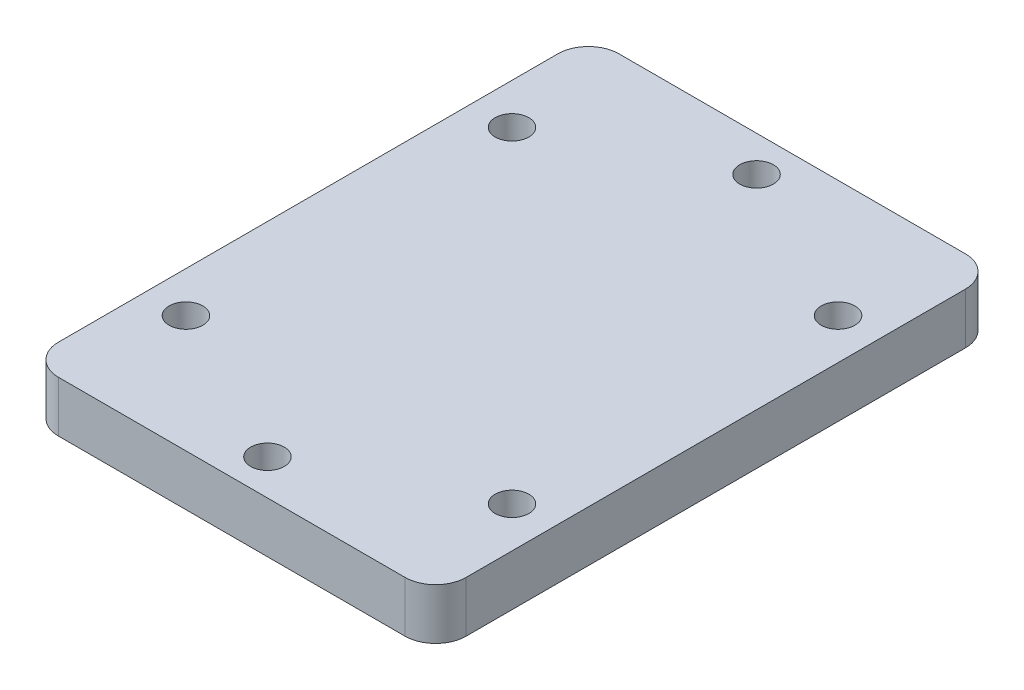
from build123d import *

# Parameters (mm, degrees)
SKETCH_1_W          = 40
SKETCH_1_H          = 55
SKETCH_1_R          = 1.65
EXTRUDE_1_DEPTH     = 5
EXTRUDE_2_DEPTH     = 3
SKETCH_3_R          = 1.65
CUT_EXTRUDE_1_DEPTH = 8.5
CUT_EXTRUDE_2_DEPTH = 2.5
FILLET_1_R          = 3


with BuildPart() as part:
    # 草图1 → 凸台-拉伸1 (new body)
    with BuildSketch(Plane(origin=(0, 0, 0), x_dir=(1, 0, 0), z_dir=(0, 1, 0))):
        Rectangle(SKETCH_1_W, SKETCH_1_H)
        with Locations((-16, 16)):
            Circle(SKETCH_1_R, mode=Mode.SUBTRACT)
        with Locations((16, 16)):
            Circle(SKETCH_1_R, mode=Mode.SUBTRACT)
        with Locations((16, -16)):
            Circle(SKETCH_1_R, mode=Mode.SUBTRACT)
        with Locations((-16, -16)):
            Circle(SKETCH_1_R, mode=Mode.SUBTRACT)
    extrude(amount=EXTRUDE_1_DEPTH)

    # 草图2 → 凸台-拉伸2 (add, symmetric)
    with BuildSketch(Plane(origin=(0, 0, 0), x_dir=(0, 0, -1), z_dir=(1, 0, 0))):
        Polygon((-18.5, 0), (-8.5, 0), (-11, -2.5), (-16, -2.5), align=None)
        Polygon((11, -2.5), (16, -2.5), (18.5, 0), (8.5, 0), align=None)
    extrude(amount=EXTRUDE_2_DEPTH, both=True)

    # 草图3 → 切除-拉伸1 (cut, through all)
    with BuildSketch(Plane(origin=(0, 5, 0), x_dir=(1, 0, 0), z_dir=(0, 1, 0))):
        with Locations((0, -24)):
            Circle(SKETCH_3_R)
        with Locations((0, 24)):
            Circle(SKETCH_3_R)
    extrude(amount=-CUT_EXTRUDE_1_DEPTH, mode=Mode.SUBTRACT)

    # 草图4 → 切除-拉伸2 (cut)
    with BuildSketch(Plane.XZ):
        Polygon((-14.383419246, 18.8), (-17.616580754, 18.8), (-19.233161507, 16), (-17.616580754, 13.2), (-14.383419246, 13.2), (-12.766838493, 16), align=None)
        Polygon((17.616580754, 18.8), (14.383419246, 18.8), (12.766838493, 16), (14.383419246, 13.2), (17.616580754, 13.2), (19.233161507, 16), align=None)
        Polygon((14.383419246, -13.2), (12.766838493, -16), (14.383419246, -18.8), (17.616580754, -18.8), (19.233161507, -16), (17.616580754, -13.2), align=None)
        Polygon((-17.616580754, -13.2), (-19.233161507, -16), (-17.616580754, -18.8), (-14.383419246, -18.8), (-12.766838493, -16), (-14.383419246, -13.2), align=None)
    extrude(amount=-CUT_EXTRUDE_2_DEPTH, mode=Mode.SUBTRACT)

    # 圆角1
    fillet_1_edges = [part.edges().sort_by_distance(p)[0] for p in [
        (20, 2.5, 27.5),
        (-20, 2.5, 27.5),
        (-20, 2.5, -27.5),
        (20, 2.5, -27.5),
    ]]
    fillet(fillet_1_edges, radius=FILLET_1_R)


solid = part.part
